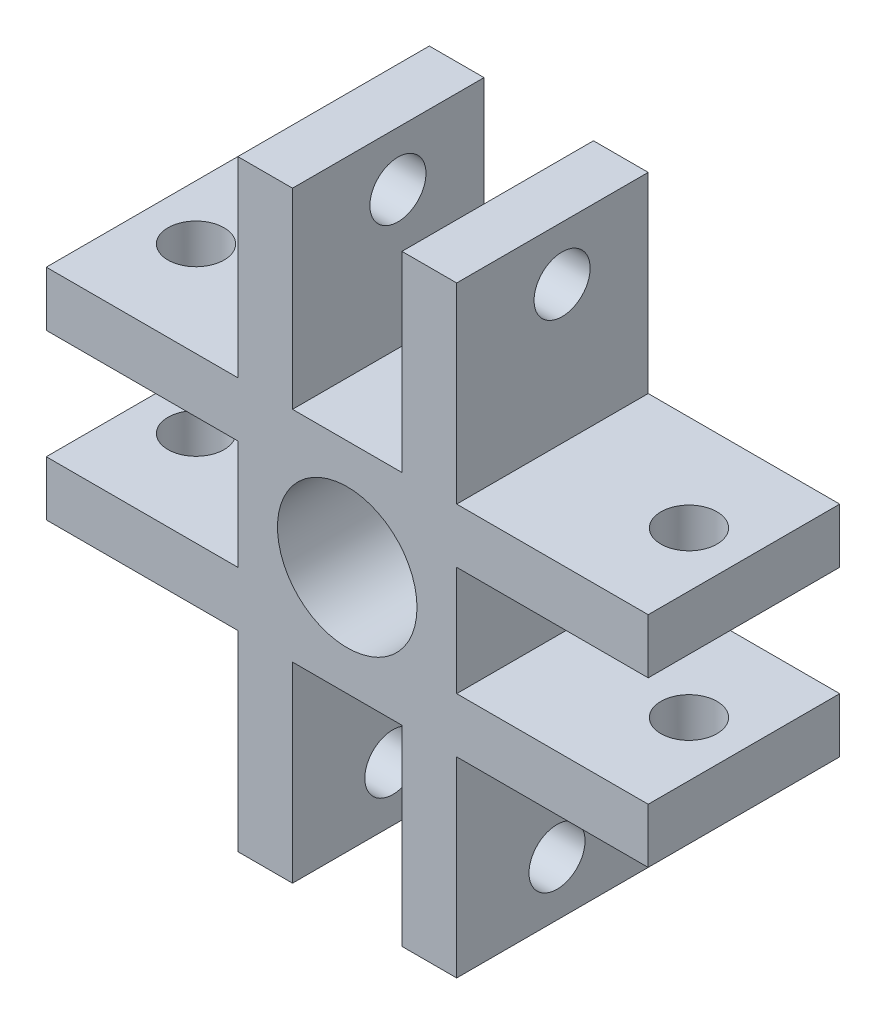
from build123d import *

# Parameters (mm, degrees)
SKETCH1_W       = 22
SKETCH1_H       = 22
EXTRUDE1_DEPTH  = 7
SKETCH2_W       = 7
SKETCH2_H       = 7
EXTRUDE2_DEPTH  = 7
SKETCH3_W       = 7
SKETCH3_H       = 4
SKETCH3_W_2     = 4
SKETCH3_H_2     = 7
EXTRUDE3_DEPTH  = 7
SKETCH4_W       = 4
SKETCH4_H       = 4
EXTRUDE5_DEPTH  = 7
SKETCH5_R       = 2.55
EXTRUDE6_DEPTH  = 10
SKETCH6_R       = 1.025
EXTRUDE7_DEPTH  = 10
SKETCH7_R       = 1.025
EXTRUDE8_DEPTH  = 10
SKETCH8_R       = 1.025
EXTRUDE9_DEPTH  = 10
SKETCH9_R       = 1.025
EXTRUDE10_DEPTH = 10


with BuildPart() as part:
    # Sketch1 → Extrude1 (new body)
    with BuildSketch(Plane.XY):
        Rectangle(SKETCH1_W, SKETCH1_H)
    extrude(amount=EXTRUDE1_DEPTH)

    # Sketch2 → Extrude2 (cut)
    with BuildSketch(Plane.XY.offset(7)):
        with Locations((7.5, 7.5)):
            Rectangle(SKETCH2_W, SKETCH2_H)
        with Locations((-7.5, 7.5)):
            Rectangle(SKETCH2_W, SKETCH2_H)
        with Locations((-7.5, -7.5)):
            Rectangle(SKETCH2_W, SKETCH2_H)
        with Locations((7.5, -7.5)):
            Rectangle(SKETCH2_W, SKETCH2_H)
    extrude(amount=-EXTRUDE2_DEPTH, mode=Mode.SUBTRACT)

    # Sketch3 → Extrude3 (cut)
    with BuildSketch(Plane.XY.offset(7)):
        with Locations((-7.5, 0)):
            Rectangle(SKETCH3_W, SKETCH3_H)
        with Locations((0, 7.5)):
            Rectangle(SKETCH3_W_2, SKETCH3_H_2)
        with Locations((7.5, 0)):
            Rectangle(SKETCH3_W, SKETCH3_H)
        with Locations((0, -7.5)):
            Rectangle(SKETCH3_W_2, SKETCH3_H_2)
        Rectangle(SKETCH3_W_2, SKETCH3_H)
    extrude(amount=-EXTRUDE3_DEPTH, mode=Mode.SUBTRACT)

    # Sketch4 → Extrude5 (add)
    with BuildSketch(Plane.XY.offset(7)):
        Rectangle(SKETCH4_W, SKETCH4_H)
    extrude(amount=-EXTRUDE5_DEPTH)

    # Sketch5 → Extrude6 (cut)
    with BuildSketch(Plane.XY.offset(7)):
        Circle(SKETCH5_R)
    extrude(amount=-EXTRUDE6_DEPTH, mode=Mode.SUBTRACT)

    # Sketch6 → Extrude7 (cut)
    with BuildSketch(Plane(origin=(4, 0, 0), x_dir=(0, 0, -1), z_dir=(1, 0, 0))):
        with Locations((-3.14721043, 9.031360998)):
            Circle(SKETCH6_R)
    extrude(amount=-EXTRUDE7_DEPTH, mode=Mode.SUBTRACT)

    # Sketch7 → Extrude8 (cut)
    with BuildSketch(Plane.XZ.offset(4)):
        with Locations((-9, 3.526976634)):
            Circle(SKETCH7_R)
    extrude(amount=-EXTRUDE8_DEPTH, mode=Mode.SUBTRACT)

    # Sketch8 → Extrude9 (cut)
    with BuildSketch(Plane(origin=(4, 0, 0), x_dir=(0, 0, -1), z_dir=(1, 0, 0))):
        with Locations((-3.332535344, -9)):
            Circle(SKETCH8_R)
    extrude(amount=-EXTRUDE9_DEPTH, mode=Mode.SUBTRACT)

    # Sketch9 → Extrude10 (cut)
    with BuildSketch(Plane(origin=(0, 4, 0), x_dir=(1, 0, 0), z_dir=(0, 1, 0))):
        with Locations((9, -3.510451641)):
            Circle(SKETCH9_R)
    extrude(amount=-EXTRUDE10_DEPTH, mode=Mode.SUBTRACT)


solid = part.part
